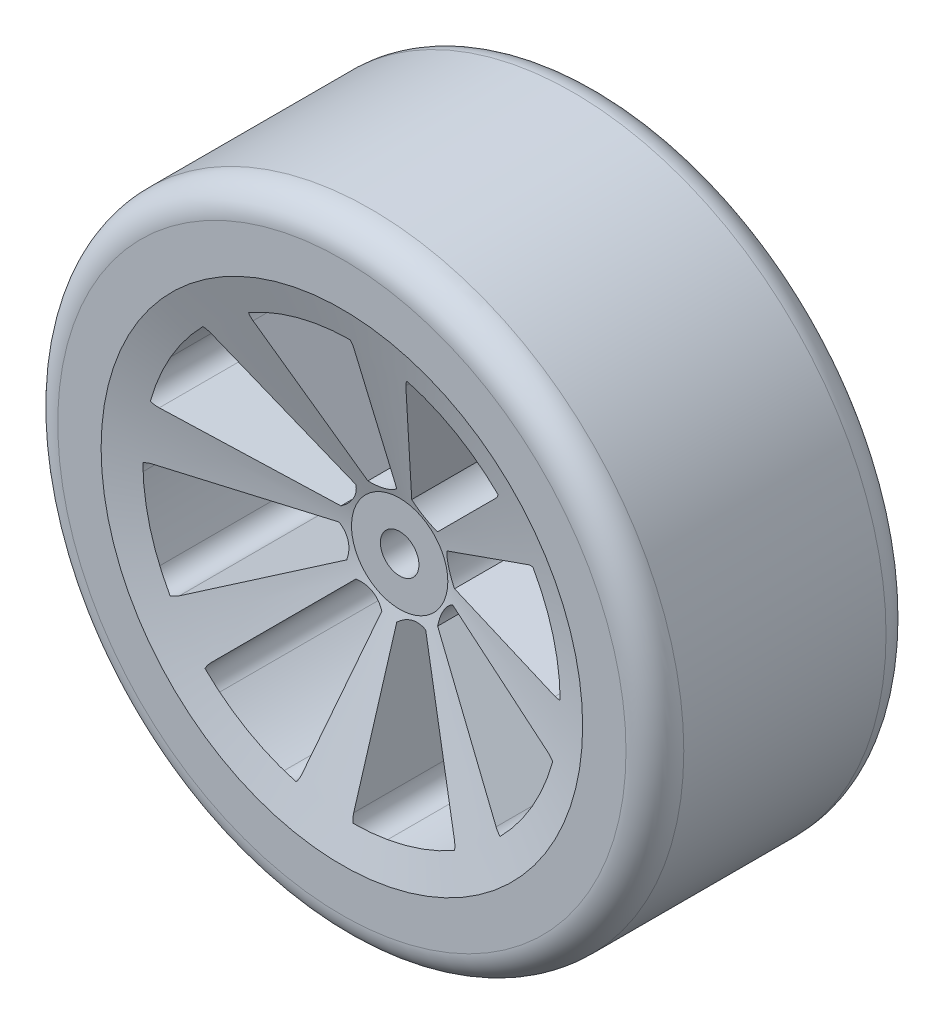
from build123d import *

# Parameters (mm, degrees)
SKETCH_1_R          = 32.5
EXTRUDE_1_DEPTH     = 27
FILLET_1_R          = 3
SKETCH_5_R          = 2
CUT_EXTRUDE_1_DEPTH = 15
CUT_EXTRUDE_2_DEPTH = 26


with BuildPart() as part:
    # 草图1 → 凸台-拉伸1 (new body)
    with BuildSketch(Plane.XY):
        Circle(SKETCH_1_R)
    extrude(amount=EXTRUDE_1_DEPTH)

    # 圆角1
    fillet_1_edges = [part.edges().sort_by_distance(p)[0] for p in [
        (-32.5, 0, 0),
        (-32.5, 0, 27),
    ]]
    fillet(fillet_1_edges, radius=FILLET_1_R)

    # 草图4 → 切除-旋转1 (revolve, cut)
    with BuildSketch(Plane(origin=(0, 0, 0), x_dir=(1, 0, 0), z_dir=(0, 1, 0))):
        Polygon((0, -27), (0, -21), (5, -21), (25, -27), align=None)
        Polygon((0, -6), (0, 0), (25, 0), (5, -6), align=None)
    revolve(axis=Axis((0, 0, 27), (0, 0, -1)), mode=Mode.SUBTRACT)

    # 草图5 → 切除-拉伸1 (cut)
    with BuildSketch(Plane.XY.offset(21)):
        Circle(SKETCH_5_R)
    extrude(amount=-CUT_EXTRUDE_1_DEPTH, mode=Mode.SUBTRACT)

    # 草图6 → 切除-拉伸2 (cut)
    with BuildSketch(Plane(origin=(0, 0, 0), x_dir=(-1, 0, 0), z_dir=(0, 0, -1))):
        with BuildLine():
            Line((6, 0), (20.90454496, 0))
            ThreePointArc((20.90454496, 0), (22.3845707, -0.654814582), (22.895454004, -2.19047619))
            ThreePointArc((22.895454004, -2.19047619), (22.216294005, -5.952838037), (20.923282894, -9.550718975))
            ThreePointArc((20.923282894, -9.550718975), (19.71301417, -10.625199288), (18.10386699, -10.45227248))
            Line((18.10386699, -10.45227248), (5.196152423, -3))
            ThreePointArc((5.196152423, -3), (5.220994192, -1.398961177), (6, 0))
        make_face()
        with BuildLine():
            Line((1.552914271, -5.795554958), (5.410494365, -20.192239864))
            ThreePointArc((5.410494365, -20.192239864), (6.42605553, -21.452356465), (8.041617067, -21.548373371))
            ThreePointArc((8.041617067, -21.548373371), (11.5, -19.918584287), (14.640630216, -17.738431353))
            ThreePointArc((14.640630216, -17.738431353), (15.365257905, -16.291305567), (14.781745499, -14.781745499))
            Line((14.781745499, -14.781745499), (4.242640687, -4.242640687))
            ThreePointArc((4.242640687, -4.242640687), (2.702585463, -4.681015333), (1.552914271, -5.795554958))
        make_face()
        with BuildLine():
            Line((-3, -5.196152423), (-10.45227248, -18.10386699))
            ThreePointArc((-10.45227248, -18.10386699), (-10.625199288, -19.71301417), (-9.550718975, -20.923282894))
            ThreePointArc((-9.550718975, -20.923282894), (-5.952838037, -22.216294005), (-2.19047619, -22.895454004))
            ThreePointArc((-2.19047619, -22.895454004), (-0.654814582, -22.3845707), (0, -20.90454496))
            Line((0, -20.90454496), (0, -6))
            ThreePointArc((0, -6), (-1.398961177, -5.220994192), (-3, -5.196152423))
        make_face()
        with BuildLine():
            Line((-5.795554958, -1.552914271), (-20.192239864, -5.410494365))
            ThreePointArc((-20.192239864, -5.410494365), (-21.452356465, -6.42605553), (-21.548373371, -8.041617067))
            ThreePointArc((-21.548373371, -8.041617067), (-19.918584287, -11.5), (-17.738431353, -14.640630216))
            ThreePointArc((-17.738431353, -14.640630216), (-16.291305567, -15.365257905), (-14.781745499, -14.781745499))
            Line((-14.781745499, -14.781745499), (-4.242640687, -4.242640687))
            ThreePointArc((-4.242640687, -4.242640687), (-4.681015333, -2.702585463), (-5.795554958, -1.552914271))
        make_face()
        with BuildLine():
            Line((-5.196152423, 3), (-18.10386699, 10.45227248))
            ThreePointArc((-18.10386699, 10.45227248), (-19.71301417, 10.625199288), (-20.923282894, 9.550718975))
            ThreePointArc((-20.923282894, 9.550718975), (-22.216294005, 5.952838037), (-22.895454004, 2.19047619))
            ThreePointArc((-22.895454004, 2.19047619), (-22.3845707, 0.654814582), (-20.90454496, 0))
            Line((-20.90454496, 0), (-6, 0))
            ThreePointArc((-6, 0), (-5.220994192, 1.398961177), (-5.196152423, 3))
        make_face()
        with BuildLine():
            Line((-1.552914271, 5.795554958), (-5.410494365, 20.192239864))
            ThreePointArc((-5.410494365, 20.192239864), (-6.42605553, 21.452356465), (-8.041617067, 21.548373371))
            ThreePointArc((-8.041617067, 21.548373371), (-11.5, 19.918584287), (-14.640630216, 17.738431353))
            ThreePointArc((-14.640630216, 17.738431353), (-15.365257905, 16.291305567), (-14.781745499, 14.781745499))
            Line((-14.781745499, 14.781745499), (-4.242640687, 4.242640687))
            ThreePointArc((-4.242640687, 4.242640687), (-2.702585463, 4.681015333), (-1.552914271, 5.795554958))
        make_face()
        with BuildLine():
            Line((3, 5.196152423), (10.45227248, 18.10386699))
            ThreePointArc((10.45227248, 18.10386699), (10.625199288, 19.71301417), (9.550718975, 20.923282894))
            ThreePointArc((9.550718975, 20.923282894), (5.952838037, 22.216294005), (2.19047619, 22.895454004))
            ThreePointArc((2.19047619, 22.895454004), (0.654814582, 22.3845707), (0, 20.90454496))
            Line((0, 20.90454496), (0, 6))
            ThreePointArc((0, 6), (1.398961177, 5.220994192), (3, 5.196152423))
        make_face()
        with BuildLine():
            Line((5.795554958, 1.552914271), (20.192239864, 5.410494365))
            ThreePointArc((20.192239864, 5.410494365), (21.452356465, 6.42605553), (21.548373371, 8.041617067))
            ThreePointArc((21.548373371, 8.041617067), (19.918584287, 11.5), (17.738431353, 14.640630216))
            ThreePointArc((17.738431353, 14.640630216), (16.291305567, 15.365257905), (14.781745499, 14.781745499))
            Line((14.781745499, 14.781745499), (4.242640687, 4.242640687))
            ThreePointArc((4.242640687, 4.242640687), (4.681015333, 2.702585463), (5.795554958, 1.552914271))
        make_face()
    extrude(amount=-CUT_EXTRUDE_2_DEPTH, mode=Mode.SUBTRACT)


solid = part.part
